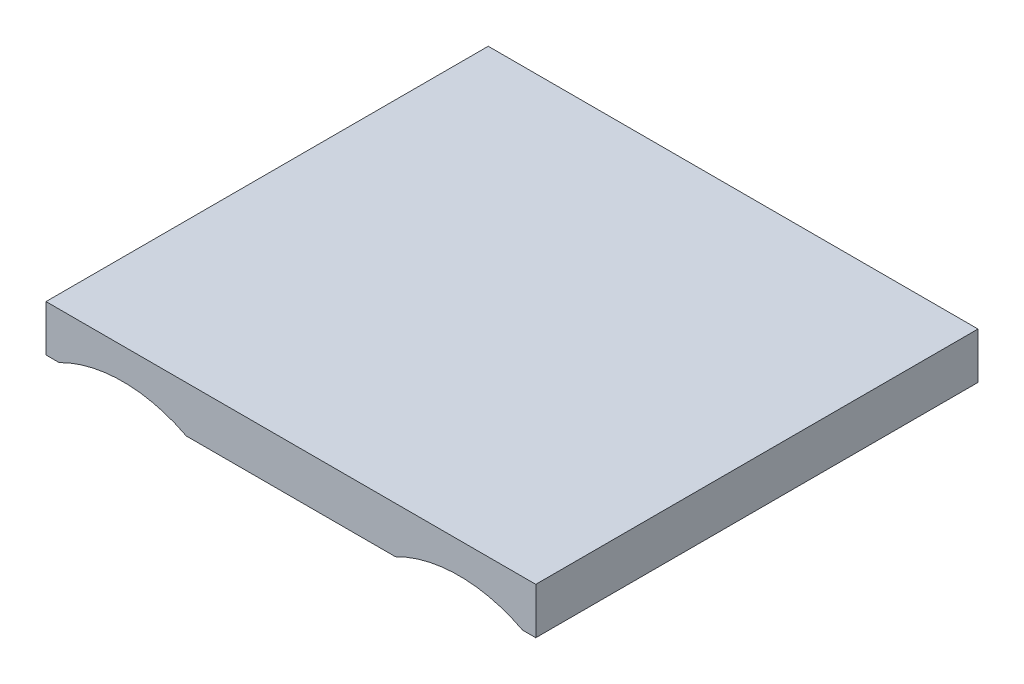
from build123d import *

# Parameters (mm, degrees)
BOSS_EXTRUDE1_DEPTH = 28.668


with BuildPart() as part:
    # Sketch1 → Boss-Extrude1 (new body)
    with BuildSketch(Plane.XY):
        with BuildLine():
            Line((-15.875, -1.5), (-15.023105626, -1.5))
            ThreePointArc((-15.023105626, -1.5), (-10.9, -0.5), (-6.776894374, -1.5))
            Line((-6.776894374, -1.5), (6.776894374, -1.5))
            ThreePointArc((6.776894374, -1.5), (10.9, -0.5), (15.023105626, -1.5))
            Line((15.023105626, -1.5), (15.875, -1.5))
            Line((15.875, -1.5), (15.875, 1.5))
            Line((15.875, 1.5), (-15.875, 1.5))
            Line((-15.875, 1.5), (-15.875, -1.5))
        make_face()
    extrude(amount=BOSS_EXTRUDE1_DEPTH)


solid = part.part
